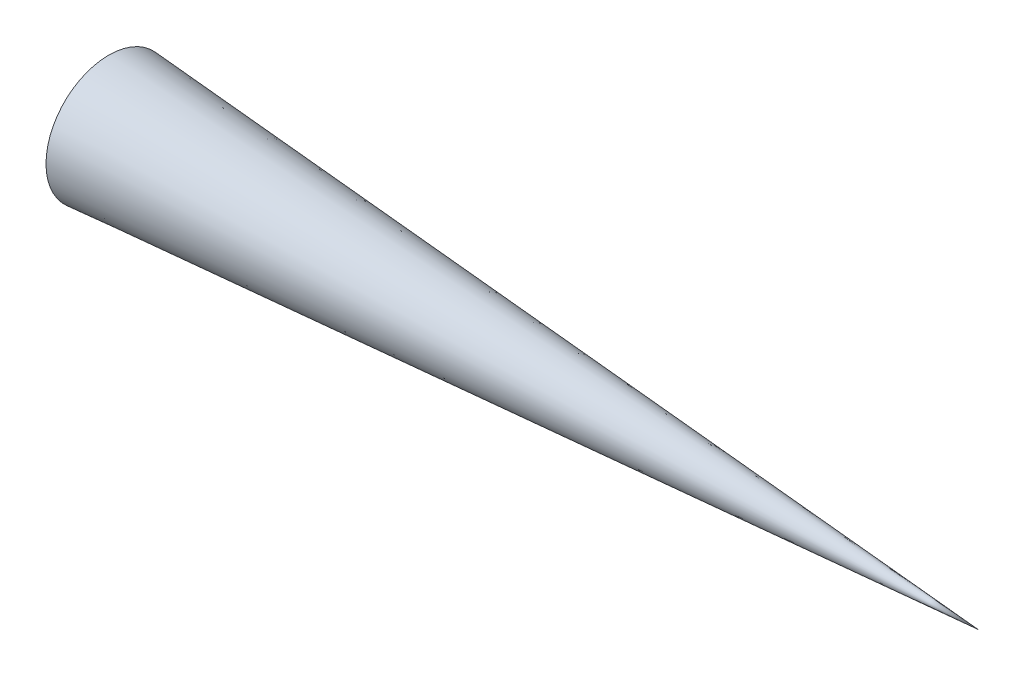
from build123d import *


with BuildPart() as part:
    # Sketch1 → Revolve1 (revolve)
    with BuildSketch(Plane.XY):
        Polygon((0, 14.505), (0, 15.266976324), (211.56, 0), (201.001019114, 0), align=None)
    revolve(axis=Axis((217.714500064, 0, 0), (-1, 0, 0)))


solid = part.part
